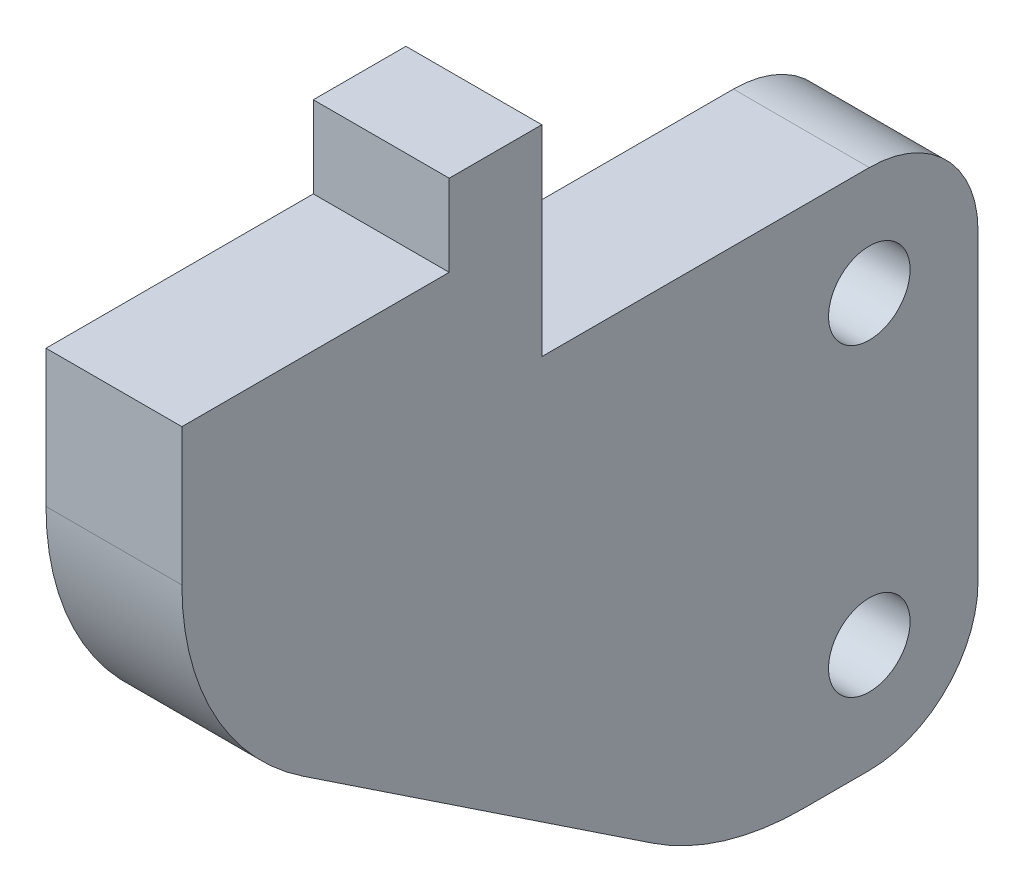
from build123d import *

# Parameters (mm, degrees)
SKETCH1_R           = 4
SKETCH1_R_2         = 1.5
BOSS_EXTRUDE1_DEPTH = 5


with BuildPart() as part:
    # Sketch1 → Boss-Extrude1 (new body)
    with BuildSketch(Plane(origin=(0, 0, 0), x_dir=(0, 0, -1), z_dir=(1, 0, 0))):
        with Locations((76.845680628, 73.944481469)):
            Circle(SKETCH1_R)
        with Locations((76.845680628, 73.944481469)):
            Circle(SKETCH1_R_2, mode=Mode.SUBTRACT)
        with Locations((76.845680628, 85.158009083)):
            Circle(SKETCH1_R)
        with Locations((76.845680628, 85.158009083)):
            Circle(SKETCH1_R_2, mode=Mode.SUBTRACT)
        with BuildLine():
            Line((80.845680628, 73.944481469), (80.845680628, 85.158009083))
            ThreePointArc((80.845680628, 85.158009083), (74.017253503, 82.329581958), (76.845680628, 89.158009083))
            Line((76.845680628, 89.158009083), (64.794938344, 89.158009083))
            Line((64.794938344, 89.158009083), (64.794938344, 96.547739715))
            Line((64.794938344, 96.547739715), (61.386991095, 96.547739715))
            Line((61.386991095, 96.547739715), (61.386991095, 93.547739715))
            Line((61.386991095, 93.547739715), (51.550416078, 93.547739715))
            Line((51.550416078, 93.547739715), (51.550416078, 88.503490644))
            ThreePointArc((51.550416078, 88.503490644), (52.73489617, 83.782621152), (56.007737829, 80.180106847))
            Line((56.007737829, 80.180106847), (68.86071523, 71.621097672))
            ThreePointArc((68.86071523, 71.621097672), (71.508038403, 70.372808732), (74.403393479, 69.944481469))
            Line((74.403393479, 69.944481469), (76.845680628, 69.944481469))
            ThreePointArc((76.845680628, 69.944481469), (74.017253503, 76.772908593), (80.845680628, 73.944481469))
        make_face()
    extrude(amount=BOSS_EXTRUDE1_DEPTH)


solid = part.part
